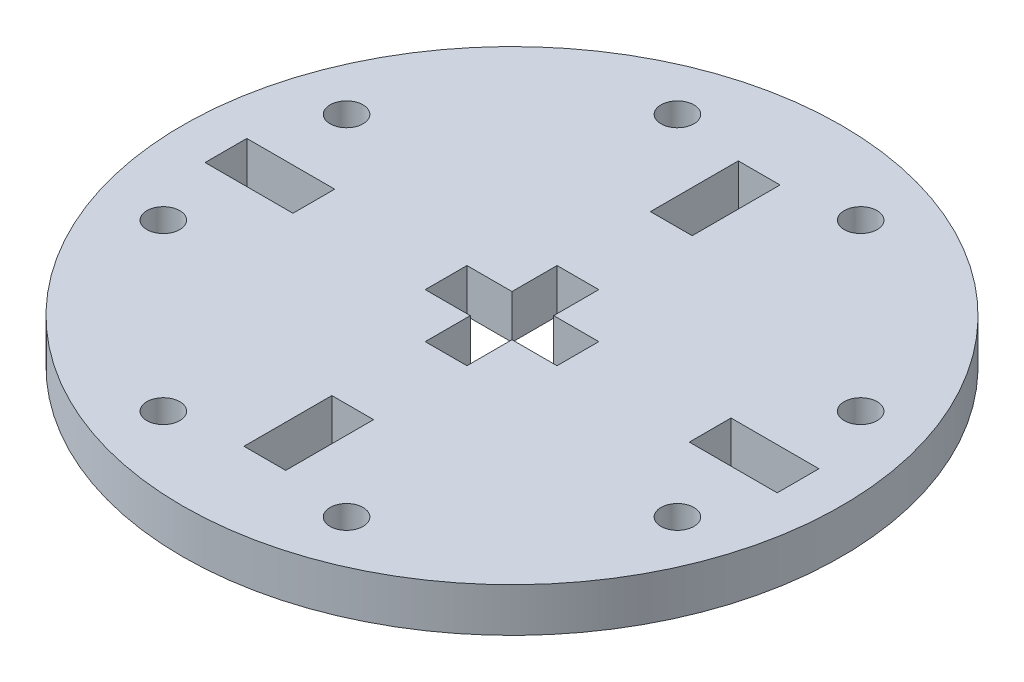
from build123d import *

# Parameters (mm, degrees)
SKETCH1_R                   = 30
BOSS_EXTRUDE1_DEPTH         = 4
CUT_EXTRUDE3_START          = 4
SKETCH1_4_W                 = 3.8
SKETCH1_4_H                 = 6
SKETCH1_4_H_2               = 8
SKETCH1_4_W_2               = 6
SKETCH1_4_H_3               = 3.8
SKETCH1_4_W_3               = 8
CUT_EXTRUDE3_DEPTH          = 5
CUT_EXTRUDE5_START          = 4
SKETCH1_5_R                 = 1.5
CUT_EXTRUDE5_DEPTH          = 5
CIRPATTERN2_COUNT           = 4
CIRPATTERN2_START           = 4
CIRPATTERN2_COPY_1_SKETCH_R = 1.5
CIRPATTERN2_COPY_1_DEPTH    = 5
CIRPATTERN2_COPY_2_SKETCH_R = 1.5
CIRPATTERN2_COPY_2_DEPTH    = 5
CIRPATTERN2_COPY_3_SKETCH_R = 1.5
CIRPATTERN2_COPY_3_DEPTH    = 5
CIRPATTERN3_COUNT           = 2


with BuildPart() as part:
    # Sketch1 → Boss-Extrude1 (new body)
    with BuildSketch(Plane(origin=(0, 0, 0), x_dir=(1, 0, 0), z_dir=(0, 1, 0))):
        Circle(SKETCH1_R)
    extrude(amount=BOSS_EXTRUDE1_DEPTH)

    # Sketch1_4 → Cut-Extrude3 (cut, through all)
    with BuildSketch(Plane(origin=(0, 0, 0), x_dir=(1, 0, 0), z_dir=(0, 1, 0)).offset(CUT_EXTRUDE3_START)):
        with Locations((0, 3)):
            Rectangle(SKETCH1_4_W, SKETCH1_4_H)
        with Locations((0, 18.5)):
            Rectangle(SKETCH1_4_W, SKETCH1_4_H_2)
        with Locations((3, 0)):
            Rectangle(SKETCH1_4_W_2, SKETCH1_4_H_3)
        with Locations((22.04, 0)):
            Rectangle(SKETCH1_4_W_3, SKETCH1_4_H_3)
    cut_extrude3 = extrude(amount=-CUT_EXTRUDE3_DEPTH, mode=Mode.SUBTRACT)

    # Sketch1_5 → Cut-Extrude5 (cut, through all)
    with BuildSketch(Plane(origin=(0, 0, 0), x_dir=(1, 0, 0), z_dir=(0, 1, 0)).offset(CUT_EXTRUDE5_START)):
        with Locations((8.34, 23.4)):
            Circle(SKETCH1_5_R)
    cut_extrude5 = extrude(amount=-CUT_EXTRUDE5_DEPTH, mode=Mode.SUBTRACT)

    # Mirror1: Cut-Extrude5 across plane
    add(cut_extrude5.mirror(Plane(origin=(0, 0, 0), x_dir=(0, 0, 1), z_dir=(1, 0, 0))), mode=Mode.SUBTRACT)

    # CirPattern2: Cut-Extrude5 ×4 about axis
    cirpattern2_axis = Axis((0, 0, 0), (0, 1, 0))
    for i in range(1, CIRPATTERN2_COUNT):
        add(cut_extrude5.rotate(cirpattern2_axis, i * 360 / CIRPATTERN2_COUNT), mode=Mode.SUBTRACT)

    # CirPattern2 copy 1 sketch → CirPattern2 copy 1 (cut, through all)
    with BuildSketch(Plane.ZX.offset(CIRPATTERN2_START)):
        with Locations((8.34, -23.4)):
            Circle(CIRPATTERN2_COPY_1_SKETCH_R)
    extrude(amount=-CIRPATTERN2_COPY_1_DEPTH, mode=Mode.SUBTRACT)

    # CirPattern2 copy 2 sketch → CirPattern2 copy 2 (cut, through all)
    with BuildSketch(Plane(origin=(0, 0, 0), x_dir=(1, 0, 0), z_dir=(0, 1, 0)).offset(CIRPATTERN2_START)):
        with Locations((8.34, -23.4)):
            Circle(CIRPATTERN2_COPY_2_SKETCH_R)
    extrude(amount=-CIRPATTERN2_COPY_2_DEPTH, mode=Mode.SUBTRACT)

    # CirPattern2 copy 3 sketch → CirPattern2 copy 3 (cut, through all)
    with BuildSketch(Plane(origin=(0, 0, 0), x_dir=(0, 0, -1), z_dir=(0, 1, 0)).offset(CIRPATTERN2_START)):
        with Locations((8.34, -23.4)):
            Circle(CIRPATTERN2_COPY_3_SKETCH_R)
    extrude(amount=-CIRPATTERN2_COPY_3_DEPTH, mode=Mode.SUBTRACT)

    # CirPattern3: Cut-Extrude3 ×2 about axis
    cirpattern3_axis = Axis((0, 0, 0), (0, 1, 0))
    for i in range(1, CIRPATTERN3_COUNT):
        add(cut_extrude3.rotate(cirpattern3_axis, i * 360 / CIRPATTERN3_COUNT), mode=Mode.SUBTRACT)


solid = part.part
